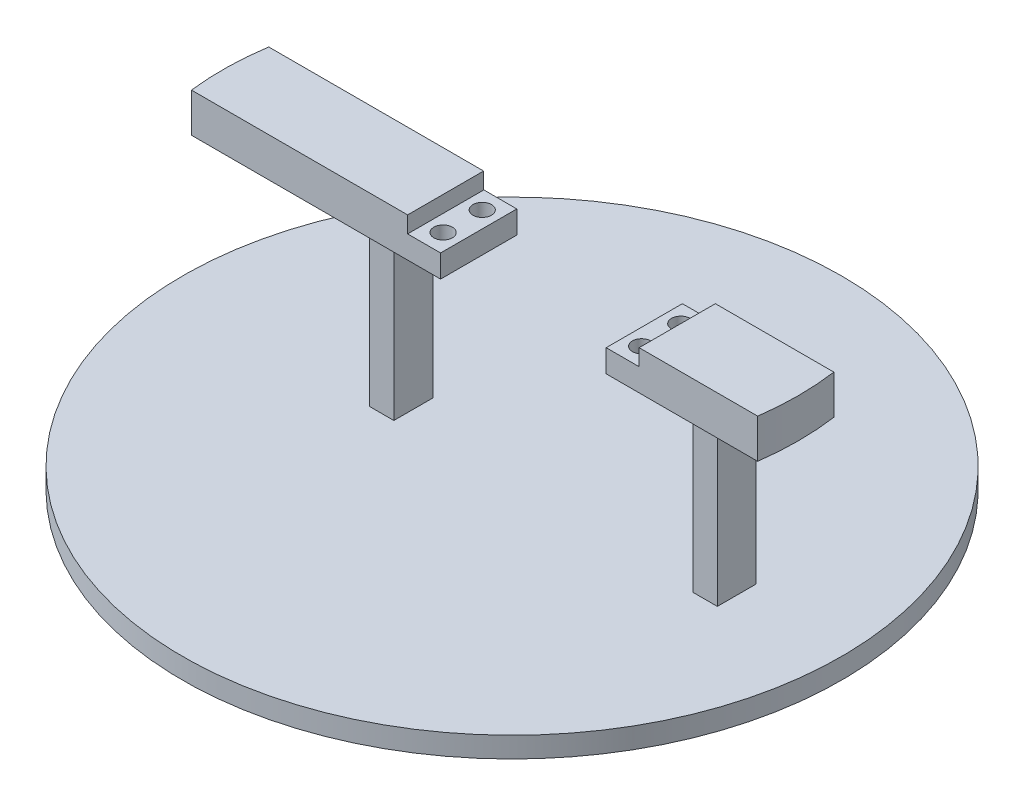
from build123d import *

# Parameters (mm, degrees)
SKETCH1_R                = 2.25
BOSS_EXTRUDE1_DEPTH      = 5.5
SKETCH1_3_W              = 5.95
SKETCH1_3_H              = 9.5
BOSS_EXTRUDE2_DEPTH      = 9.5
SKETCH1_4_R              = 2.25
BOSS_EXTRUDE3_DEPTH      = 5.5
SKETCH1_5_W              = 5.946489343
SKETCH1_5_H              = 9.324210581
BOSS_EXTRUDE4_DEPTH      = 9.5
BOSS_EXTRUDE5_DEPTH      = 9.5
BOSS_EXTRUDE5_DEPTH_BACK = 45
SKETCH1_6_W              = 5.95
SKETCH1_6_H              = 9.5
SKETCH1_6_W_2            = 5.946489343
SKETCH1_6_H_2            = 9.324210581
SKETCH2_R                = 80
BOSS_EXTRUDE6_DEPTH      = 5


with BuildPart() as part:
    # Sketch1 → Boss-Extrude1 (new body)
    with BuildSketch(Plane(origin=(0, 0, 0), x_dir=(1, 0, 0), z_dir=(0, 1, 0))):
        Polygon((-8.015677219, 18.554747116), (-16.015677219, 18.554747116), (-16.015677219, 18.5), (-16.015677219, 0.054747116), (-15.609707421, 0.054747116), (-8.409707421, 0.054747116), (-8.015677219, 0.054747116), align=None)
        with Locations((-12.009707421, 4.656325954)):
            Circle(SKETCH1_R, mode=Mode.SUBTRACT)
        with Locations((-12.009707421, 14.156325954)):
            Circle(SKETCH1_R, mode=Mode.SUBTRACT)
    extrude(amount=BOSS_EXTRUDE1_DEPTH)

    # Sketch1_3 → Boss-Extrude2 (add)
    with BuildSketch(Plane(origin=(0, 0, 0), x_dir=(1, 0, 0), z_dir=(0, 1, 0))):
        with BuildLine():
            Line((-16.015677219, 0.054747116), (-16.015677219, 18.5))
            Line((-16.015677219, 18.5), (-68.166690169, 18.5))
            ThreePointArc((-68.166690169, 18.5), (-68.959479844, 9.288334925), (-68.486040188, 0.054747116))
            Line((-68.486040188, 0.054747116), (-16.015677219, 0.054747116))
        make_face()
        with Locations((-26.93769232, 9.406325954)):
            Rectangle(SKETCH1_3_W, SKETCH1_3_H, mode=Mode.SUBTRACT)
    extrude(amount=BOSS_EXTRUDE2_DEPTH)



with BuildPart() as body_2:
    # Sketch1_4 → Boss-Extrude3 (new body)
    with BuildSketch(Plane(origin=(0, 0, 0), x_dir=(1, 0, 0), z_dir=(0, 1, 0))):
        Polygon((39.998888009, 18.73618908), (31.998888009, 18.73618908), (31.998888009, 0.23618908), (32.404857807, 0.23618908), (39.604857807, 0.23618908), (39.998888009, 0.23618908), align=None)
        with Locations((36.004857807, 4.837767918)):
            Circle(SKETCH1_4_R, mode=Mode.SUBTRACT)
        with Locations((36.004857807, 14.337767918)):
            Circle(SKETCH1_4_R, mode=Mode.SUBTRACT)
    extrude(amount=BOSS_EXTRUDE3_DEPTH)

    # Sketch1_5 → Boss-Extrude4 (add)
    with BuildSketch(Plane(origin=(0, 0, 0), x_dir=(1, 0, 0), z_dir=(0, 1, 0))):
        with BuildLine():
            Line((68.768167169, 18.73618908), (39.998888009, 18.73618908))
            Line((39.998888009, 18.73618908), (39.998888009, 0.23618908))
            Line((39.998888009, 0.23618908), (68.777433584, 0.23618908))
            ThreePointArc((68.777433584, 0.23618908), (69.409600563, 9.486508045), (68.768167169, 18.73618908))
        make_face()
        with Locations((51.410282917, 9.499873209)):
            Rectangle(SKETCH1_5_W, SKETCH1_5_H, mode=Mode.SUBTRACT)
    extrude(amount=BOSS_EXTRUDE4_DEPTH)


with BuildPart() as part_1:
    add(part.part)

    add(body_2.part)  # Boss-Extrude5 merges body 2
    # Sketch1_6 → Boss-Extrude5 (add, two sides: drawn at the far end of the back side and taken through both)
    with BuildSketch(Plane(origin=(0, 0, 0), x_dir=(1, 0, 0), z_dir=(0, 1, 0)).offset(-BOSS_EXTRUDE5_DEPTH_BACK)):
        with Locations((-26.93769232, 9.406325954)):
            Rectangle(SKETCH1_6_W, SKETCH1_6_H)
        with Locations((51.410282917, 9.499873209)):
            Rectangle(SKETCH1_6_W_2, SKETCH1_6_H_2)
    extrude(amount=BOSS_EXTRUDE5_DEPTH + BOSS_EXTRUDE5_DEPTH_BACK)

    # Sketch2 → Boss-Extrude6 (add)
    with BuildSketch(Plane.XZ.offset(45)):
        with Locations((-0.015677219, -9.406325954)):
            Circle(SKETCH2_R)
    extrude(amount=-BOSS_EXTRUDE6_DEPTH)


solid = part_1.part
